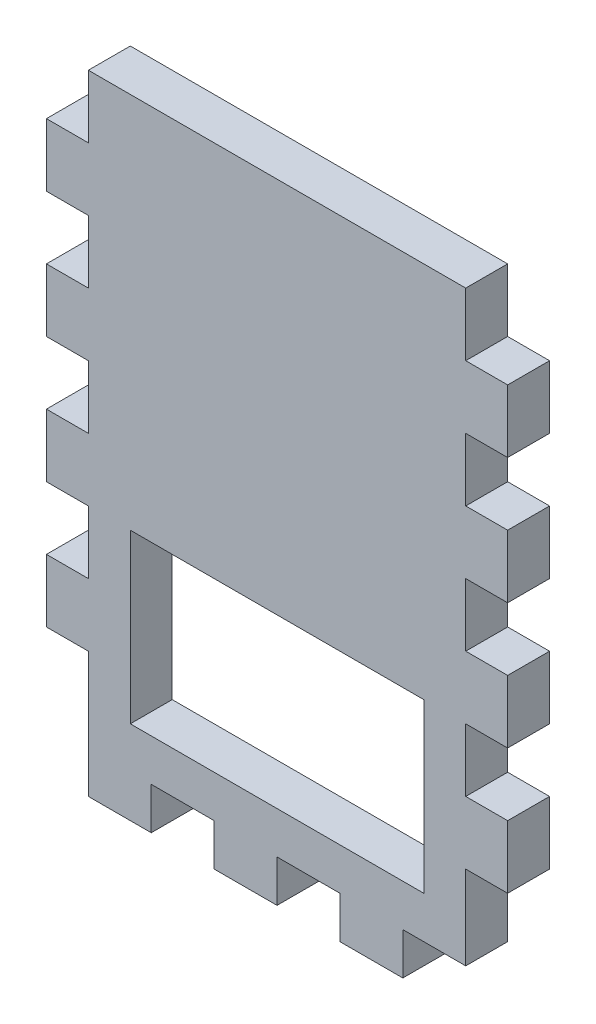
from build123d import *

# Parameters (mm, degrees)
SKETCH1_W           = 57.15
SKETCH1_H           = 88.9
SKETCH1_W_2         = 44.45
SKETCH1_H_2         = 25.4
BOSS_EXTRUDE1_DEPTH = 6.35
SKETCH2_W           = 6.35
SKETCH2_H           = 9.525
SKETCH2_W_2         = 9.525
SKETCH2_H_2         = 6.35
BOSS_EXTRUDE3_DEPTH = 6.35


with BuildPart() as part:
    # Sketch1 → Boss-Extrude1 (new body)
    with BuildSketch(Plane.XY):
        with Locations((28.575, -44.45)):
            Rectangle(SKETCH1_W, SKETCH1_H)
        with Locations((28.575, -69.85)):
            Rectangle(SKETCH1_W_2, SKETCH1_H_2, mode=Mode.SUBTRACT)
    extrude(amount=BOSS_EXTRUDE1_DEPTH)

    # Sketch2 → Boss-Extrude3 (add)
    with BuildSketch(Plane.XY.offset(6.35)):
        with Locations((-3.175, -14.2875)):
            Rectangle(SKETCH2_W, SKETCH2_H)
        with Locations((-3.175, -33.3375)):
            Rectangle(SKETCH2_W, SKETCH2_H)
        with Locations((-3.175, -52.3875)):
            Rectangle(SKETCH2_W, SKETCH2_H)
        with Locations((-3.175, -71.4375)):
            Rectangle(SKETCH2_W, SKETCH2_H)
        with Locations((4.7625, -92.075)):
            Rectangle(SKETCH2_W_2, SKETCH2_H_2)
        with Locations((23.8125, -92.075)):
            Rectangle(SKETCH2_W_2, SKETCH2_H_2)
        with Locations((42.8625, -92.075)):
            Rectangle(SKETCH2_W_2, SKETCH2_H_2)
        with Locations((60.325, -14.2875)):
            Rectangle(SKETCH2_W, SKETCH2_H)
        with Locations((60.325, -33.3375)):
            Rectangle(SKETCH2_W, SKETCH2_H)
        with Locations((60.325, -71.4375)):
            Rectangle(SKETCH2_W, SKETCH2_H)
        with Locations((60.325, -52.3875)):
            Rectangle(SKETCH2_W, SKETCH2_H)
    extrude(amount=-BOSS_EXTRUDE3_DEPTH)


solid = part.part
